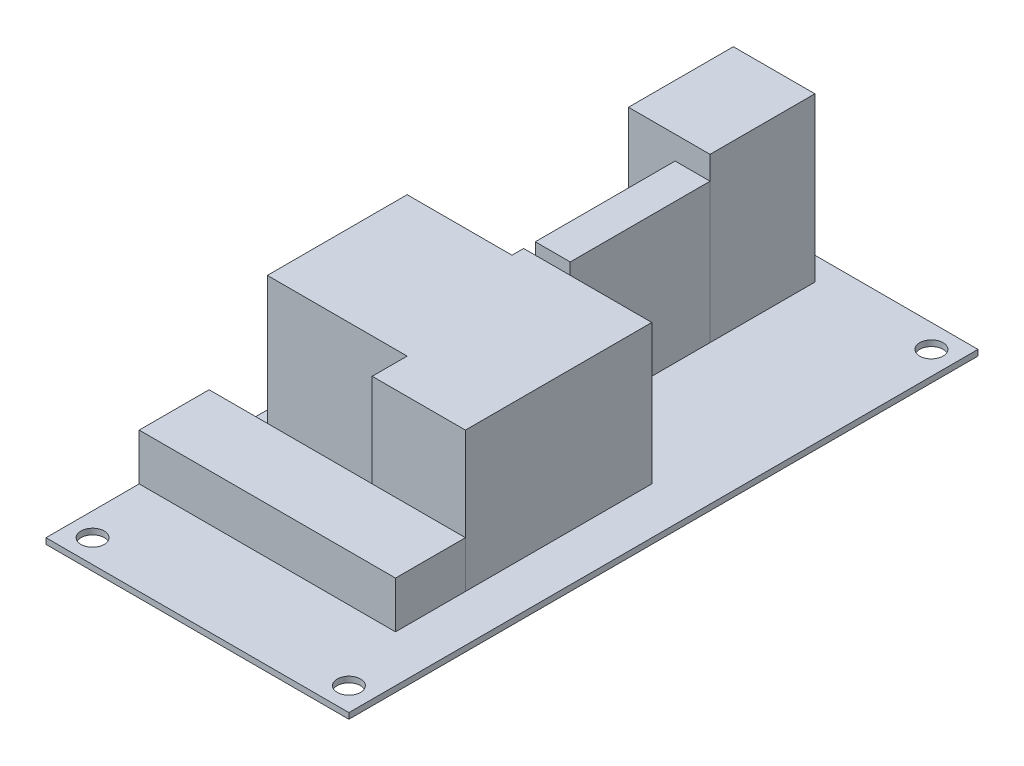
from build123d import *

# Parameters (mm, degrees)
SKETCH1_W           = 41.275
SKETCH1_H           = 85.725
BOSS_EXTRUDE1_DEPTH = 0.79375
SKETCH2_W           = 34.925
SKETCH2_H           = 9.525
BOSS_EXTRUDE2_DEPTH = 6.35
BOSS_EXTRUDE3_DEPTH = 19.05
SKETCH4_W           = 11.1125
SKETCH4_H           = 11.1125
BOSS_EXTRUDE4_DEPTH = 6.35
SKETCH5_R           = 2.38125
BOSS_EXTRUDE5_DEPTH = 3.175
SKETCH6_W           = 4.7625
SKETCH6_H           = 19.05
BOSS_EXTRUDE6_DEPTH = 19.05
SKETCH7_W           = 11.1125
SKETCH7_H           = 14.2875
BOSS_EXTRUDE7_DEPTH = 22.225
SKETCH8_R           = 1.5875
CUT_EXTRUDE1_DEPTH  = 1.79375


with BuildPart() as part:
    # Sketch1 → Boss-Extrude1 (new body)
    with BuildSketch(Plane(origin=(0, 0, 0), x_dir=(1, 0, 0), z_dir=(0, 1, 0))):
        Rectangle(SKETCH1_W, SKETCH1_H)
    extrude(amount=BOSS_EXTRUDE1_DEPTH)

    # Sketch8 → Cut-Extrude1 (cut, through all)
    with BuildSketch(Plane(origin=(0, 0.79375, 0), x_dir=(1, 0, 0), z_dir=(0, 1, 0))):
        with Locations((-17.4625, 39.6875)):
            Circle(SKETCH8_R)
        with Locations((17.4625, 39.6875)):
            Circle(SKETCH8_R)
        with Locations((-17.4625, -39.6875)):
            Circle(SKETCH8_R)
        with Locations((17.4625, -39.6875)):
            Circle(SKETCH8_R)
    extrude(amount=-CUT_EXTRUDE1_DEPTH, mode=Mode.SUBTRACT)


with BuildPart() as body_2:
    # Sketch2 → Boss-Extrude2 (new body)
    with BuildSketch(Plane(origin=(0, 0.79375, 0), x_dir=(1, 0, 0), z_dir=(0, 1, 0))):
        with Locations((-3.175, -25.4)):
            Rectangle(SKETCH2_W, SKETCH2_H)
    extrude(amount=BOSS_EXTRUDE2_DEPTH)


with BuildPart() as body_3:
    # Sketch3 → Boss-Extrude3 (new body)
    with BuildSketch(Plane(origin=(0, 0.79375, 0), x_dir=(1, 0, 0), z_dir=(0, 1, 0))):
        Polygon((14.2875, -20.6375), (14.2875, 4.7625), (-3.175, 4.7625), (-3.175, 3.175), (-17.4625, 3.175), (-17.4625, -15.875), (1.5875, -15.875), (1.5875, -20.6375), align=None)
    extrude(amount=BOSS_EXTRUDE3_DEPTH)


with BuildPart() as body_4:
    # Sketch4 → Boss-Extrude4 (new body)
    with BuildSketch(Plane(origin=(0, 0.79375, 0), x_dir=(1, 0, 0), z_dir=(0, 1, 0))):
        with Locations((-8.73125, 15.08125)):
            Rectangle(SKETCH4_W, SKETCH4_H)
    extrude(amount=BOSS_EXTRUDE4_DEPTH)


with BuildPart() as body_5:
    # Sketch5 → Boss-Extrude5 (new body)
    with BuildSketch(Plane(origin=(0, 7.14375, 0), x_dir=(1, 0, 0), z_dir=(0, 1, 0))):
        with Locations((-8.73125, 15.08125)):
            Circle(SKETCH5_R)
    extrude(amount=BOSS_EXTRUDE5_DEPTH)


with BuildPart() as body_6:
    # Sketch6 → Boss-Extrude6 (new body)
    with BuildSketch(Plane(origin=(0, 0.79375, 0), x_dir=(1, 0, 0), z_dir=(0, 1, 0))):
        with Locations((-0.79375, 15.875)):
            Rectangle(SKETCH6_W, SKETCH6_H)
    extrude(amount=BOSS_EXTRUDE6_DEPTH)


with BuildPart() as body_7:
    # Sketch7 → Boss-Extrude7 (new body)
    with BuildSketch(Plane(origin=(0, 0.79375, 0), x_dir=(1, 0, 0), z_dir=(0, 1, 0))):
        with Locations((-3.96875, 32.54375)):
            Rectangle(SKETCH7_W, SKETCH7_H)
    extrude(amount=BOSS_EXTRUDE7_DEPTH)


solid = Compound([part.part, body_2.part, body_3.part, body_4.part, body_5.part, body_6.part, body_7.part])
